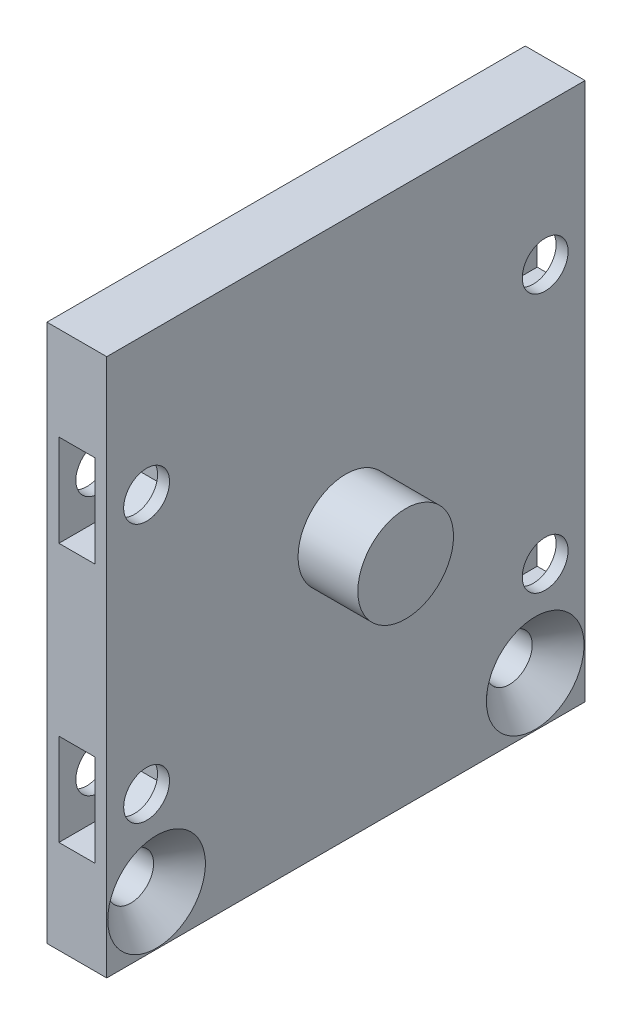
from build123d import *

# Parameters (mm, degrees)
SKETCH1_W           = 24
SKETCH1_H           = 27
SKETCH1_R           = 1.15
BOSS_EXTRUDE1_DEPTH = 3
SKETCH2_R           = 2.4
BOSS_EXTRUDE2_DEPTH = 3
CHAMFER1_SIZE       = 1.3
SKETCH3_R           = 1.15
CUT_EXTRUDE1_DEPTH  = 3
CUT_EXTRUDE2_START  = 0.6
CUT_EXTRUDE2_DEPTH  = 1.8
SKETCH5_W           = 2
SKETCH5_H           = 4.618802154
CUT_EXTRUDE3_DEPTH  = 1.8


with BuildPart() as part:
    # Sketch1 → Boss-Extrude1 (new body)
    with BuildSketch(Plane(origin=(0, 0, 0), x_dir=(0, 0, -1), z_dir=(1, 0, 0))):
        Rectangle(SKETCH1_W, SKETCH1_H)
        with Locations((-9.5, -11)):
            Circle(SKETCH1_R, mode=Mode.SUBTRACT)
        with Locations((9.5, -11)):
            Circle(SKETCH1_R, mode=Mode.SUBTRACT)
    extrude(amount=BOSS_EXTRUDE1_DEPTH)

    # Sketch2 → Boss-Extrude2 (add)
    with BuildSketch(Plane(origin=(3, 0, 0), x_dir=(0, 0, -1), z_dir=(1, 0, 0))):
        Circle(SKETCH2_R)
    extrude(amount=BOSS_EXTRUDE2_DEPTH)

    # Chamfer1
    chamfer1_edges = [part.edges().sort_by_distance(p)[0] for p in [
        (3, -11, 10.65),
        (3, -11, -8.35),
    ]]
    chamfer(chamfer1_edges, length=CHAMFER1_SIZE)

    # Sketch3 → Cut-Extrude1 (cut)
    with BuildSketch(Plane(origin=(0, 0, 0), x_dir=(0, 0, -1), z_dir=(1, 0, 0))):
        with Locations((-10, 6.5)):
            Circle(SKETCH3_R)
        with Locations((-10, -6.5)):
            Circle(SKETCH3_R)
        with Locations((10, -6.5)):
            Circle(SKETCH3_R)
        with Locations((10, 6.5)):
            Circle(SKETCH3_R)
    extrude(amount=CUT_EXTRUDE1_DEPTH, mode=Mode.SUBTRACT)

    # Sketch4 → Cut-Extrude2 (cut)
    with BuildSketch(Plane(origin=(0, 0, 0), x_dir=(0, 0, -1), z_dir=(1, 0, 0)).offset(CUT_EXTRUDE2_START)):
        Polygon((-10, 4.190598923), (-8, 5.345299462), (-8, 7.654700538), (-10, 8.809401077), (-12, 7.654700538), (-12, 5.345299462), align=None)
        Polygon((-10, -4.190598923), (-12, -5.345299462), (-12, -7.654700538), (-10, -8.809401077), (-8, -7.654700538), (-8, -5.345299462), align=None)
        Polygon((10, -4.190598923), (8, -5.345299462), (8, -7.654700538), (10, -8.809401077), (12, -7.654700538), (12, -5.345299462), align=None)
        Polygon((10, 8.809401077), (8, 7.654700538), (8, 5.345299462), (10, 4.190598923), (12, 5.345299462), (12, 7.654700538), align=None)
    extrude(amount=CUT_EXTRUDE2_DEPTH, mode=Mode.SUBTRACT)

    # Sketch5 → Cut-Extrude3 (cut)
    with BuildSketch(Plane(origin=(0.6, 0, 0), x_dir=(0, 0, -1), z_dir=(1, 0, 0))):
        with Locations((-11, 6.5)):
            Rectangle(SKETCH5_W, SKETCH5_H)
        with Locations((-11, -6.5)):
            Rectangle(SKETCH5_W, SKETCH5_H)
        with Locations((11, 6.5)):
            Rectangle(SKETCH5_W, SKETCH5_H)
        with Locations((11, -6.5)):
            Rectangle(SKETCH5_W, SKETCH5_H)
    extrude(amount=CUT_EXTRUDE3_DEPTH, mode=Mode.SUBTRACT)


solid = part.part
